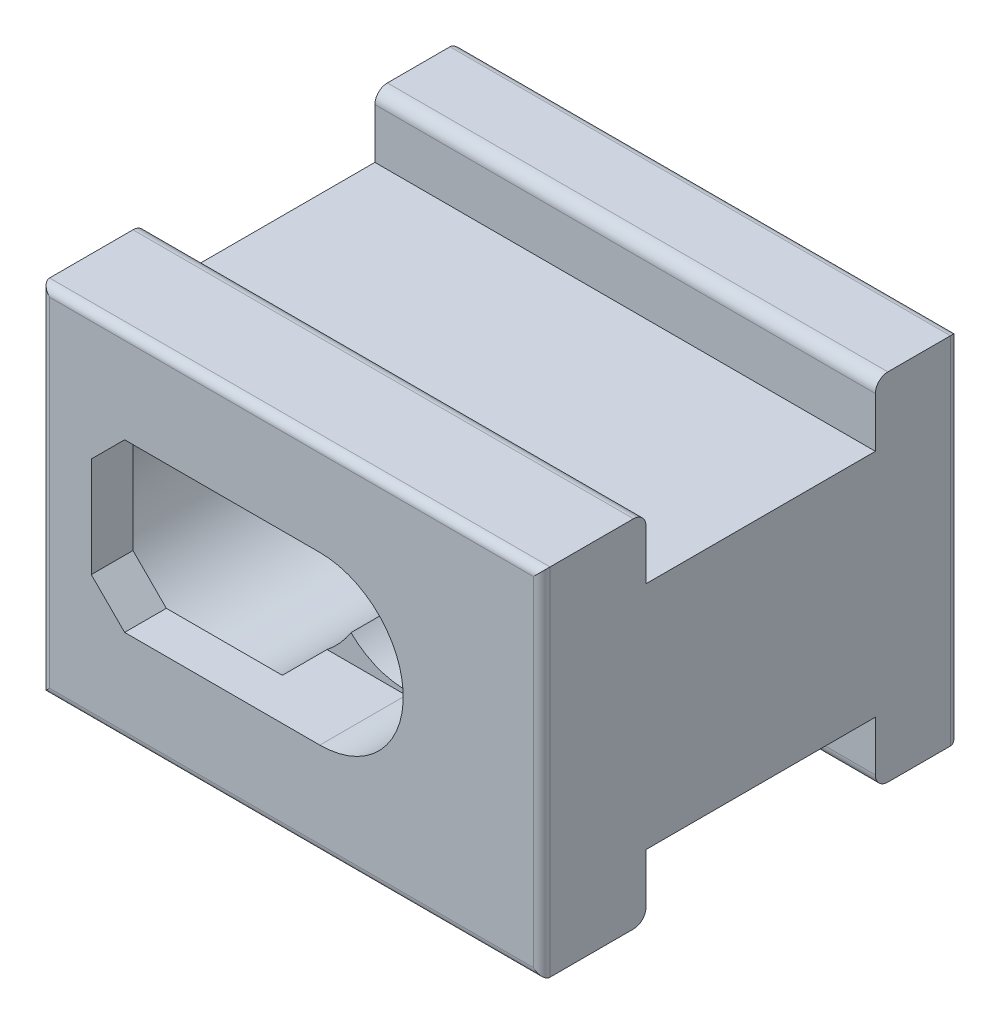
from build123d import *

# Parameters (mm, degrees)
ESQUISSE1_W             = 120
ESQUISSE1_H             = 85.2
BOSS_EXTRU_1_DEPTH      = 100
ESQUISSE2_W             = 55
ESQUISSE2_H             = 15
ENL_V_MAT_EXTRU_1_DEPTH = 121
CONG_1_R                = 3
CONG_2_R                = 2
CONG_3_R                = 2
ESQUISSE3_R             = 25.5
ENL_V_MAT_EXTRU_2_DEPTH = 90
CONG_4_R                = 1
ENL_V_MAT_EXTRU_3_DEPTH = 20.7
ESQUISSE6_R             = 19
ENL_V_MAT_EXTRU_5_DEPTH = 85


with BuildPart() as part:
    # Esquisse1 → Boss.-Extru.1 (new body)
    with BuildSketch(Plane.XY):
        Rectangle(ESQUISSE1_W, ESQUISSE1_H)
    extrude(amount=BOSS_EXTRU_1_DEPTH)

    # Esquisse2 → Enlèv. mat.-Extru.1 (cut, through all)
    with BuildSketch(Plane.ZY.offset(60)):
        with Locations((47.5, 35.1)):
            Rectangle(ESQUISSE2_W, ESQUISSE2_H)
        with Locations((47.5, -35.1)):
            Rectangle(ESQUISSE2_W, ESQUISSE2_H)
    extrude(amount=-ENL_V_MAT_EXTRU_1_DEPTH, mode=Mode.SUBTRACT)

    # Congé1
    cong_1_edges = [part.edges().sort_by_distance(p)[0] for p in [
        (0, 42.6, 75),
        (0, 42.6, 20),
        (0, -42.6, 20),
        (0, -42.6, 75),
    ]]
    fillet(cong_1_edges, radius=CONG_1_R)

    # Congé2
    cong_2_edges = [part.edges().sort_by_distance(p)[0] for p in [
        (0, -42.6, 0),
        (-60, 0, 0),
        (0, 42.6, 0),
        (60, 0, 0),
    ]]
    fillet(cong_2_edges, radius=CONG_2_R)

    # Congé3
    cong_3_edges = [part.edges().sort_by_distance(p)[0] for p in [
        (-60, 0, 100),
        (0, -42.6, 100),
        (60, 0, 100),
        (0, 42.6, 100),
    ]]
    fillet(cong_3_edges, radius=CONG_3_R)

    # Esquisse3 → Enlèv. mat.-Extru.2 (cut)
    with BuildSketch(Plane(origin=(0, 0, 0), x_dir=(-1, 0, 0), z_dir=(0, 0, -1))):
        with Locations((28, 0)):
            Circle(ESQUISSE3_R)
    extrude(amount=-ENL_V_MAT_EXTRU_2_DEPTH, mode=Mode.SUBTRACT)

    # Congé4
    cong_4_edges = [part.edges().sort_by_distance(p)[0] for p in [
        (-2.5, 0, 0),
    ]]
    fillet(cong_4_edges, radius=CONG_4_R)

    # Esquisse5 → Enlèv. mat.-Extru.3 (cut)
    with BuildSketch(Plane.XY.offset(100)):
        with BuildLine():
            Line((-48, 0), (-48, 12))
            Line((-48, 12), (-40, 20))
            Line((-40, 20), (-28, 20))
            Line((-28, 20), (6.8, 20))
            ThreePointArc((6.8, 20), (26.8, 0), (6.8, -20))
            Line((6.8, -20), (-28, -20))
            Line((-28, -20), (-40, -20))
            Line((-40, -20), (-48, -12))
            Line((-48, -12), (-48, 0))
        make_face()
    extrude(amount=-ENL_V_MAT_EXTRU_3_DEPTH, mode=Mode.SUBTRACT)

    # Esquisse6 → Enlèv. mat.-Extru.5 (cut)
    with BuildSketch(Plane.XY.offset(79.3)):
        with Locations((6.8, 0)):
            Circle(ESQUISSE6_R)
    extrude(amount=-ENL_V_MAT_EXTRU_5_DEPTH, mode=Mode.SUBTRACT)


solid = part.part
